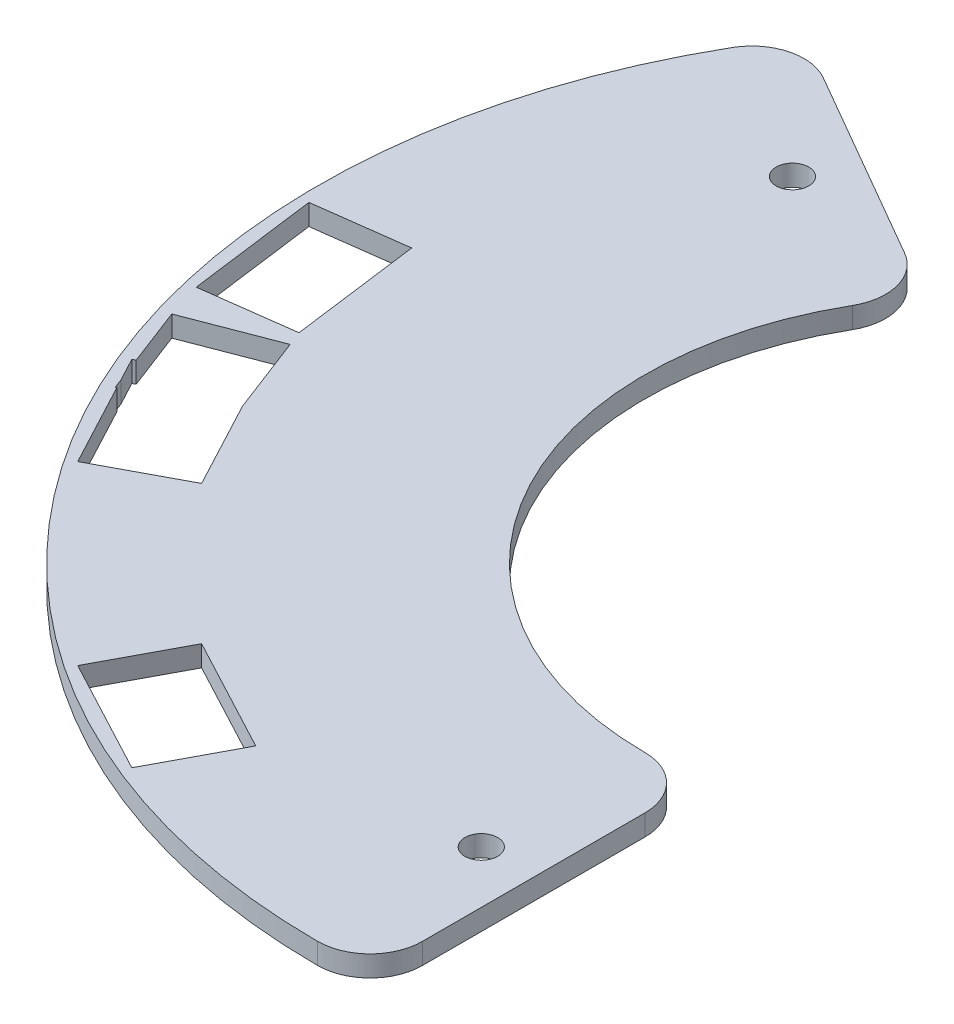
from build123d import *

# Parameters (mm, degrees)
SKETCH3_R               = 1.25
BOSS_EXTRUDE2_DEPTH     = 0.8
CUT_EXTRUDE1_DEPTH      = 1.8
CUT_EXTRUDE1_DEPTH_BACK = 1.8
FILLET1_R               = 4


with BuildPart() as part:
    # Sketch3 → Boss-Extrude2 (new body, symmetric)
    with BuildSketch(Plane(origin=(0, 0, 0), x_dir=(1, 0, 0), z_dir=(0, 1, 0))):
        with BuildLine():
            Line((-41.16248371, 28.383973204), (-19.371710273, 15.803064294))
            ThreePointArc((-19.371710273, 15.803064294), (-21.650635095, -12.5), (4, -24.677925359))
            Line((4, -24.677925359), (4, -49.839743178))
            ThreePointArc((4, -49.839743178), (-43.301270189, -25), (-41.16248371, 28.383973204))
        make_face()
        with Locations((-32.475952642, 18.75)):
            Circle(SKETCH3_R, mode=Mode.SUBTRACT)
        with Locations((0, -37.5)):
            Circle(SKETCH3_R, mode=Mode.SUBTRACT)
    extrude(amount=BOSS_EXTRUDE2_DEPTH, both=True)

    # Sketch4 → Cut-Extrude1 (cut, two sides)
    with BuildSketch(Plane(origin=(0, 0, 0), x_dir=(1, 0, 0), z_dir=(0, 1, 0))) as cut_extrude1_sk:
        Polygon((-24.132543601, -34.736441086), (-15.303067673, -39.431156714), (-18.589368612, -45.611789864), (-27.418844541, -40.917074236), align=None)
        Polygon((-39.431156714, -15.303067673), (-34.736441086, -24.132543601), (-40.917074236, -27.418844541), (-45.611789864, -18.589368612), align=None)
        Polygon((-40.554257724, -11.550527282), (-37.866498102, -18.55238048), (-44.401561088, -21.060956127), (-47.089320709, -14.059102928), align=None)
        Polygon((-42.293315139, -0.524875766), (-40.988053217, -10.43932438), (-47.928167246, -11.353007726), (-49.233429168, -1.438559112), align=None)
    extrude(amount=CUT_EXTRUDE1_DEPTH, mode=Mode.SUBTRACT)
    extrude(cut_extrude1_sk.sketch, amount=-CUT_EXTRUDE1_DEPTH_BACK, mode=Mode.SUBTRACT)

    # Fillet1
    fillet1_edges = [part.edges().sort_by_distance(p)[0] for p in [
        (-41.16248371, 0, -28.383973204),
        (-19.371710273, 0, -15.803064294),
        (4, 0, 24.677925359),
        (4, 0, 49.839743178),
    ]]
    fillet(fillet1_edges, radius=FILLET1_R)


solid = part.part
